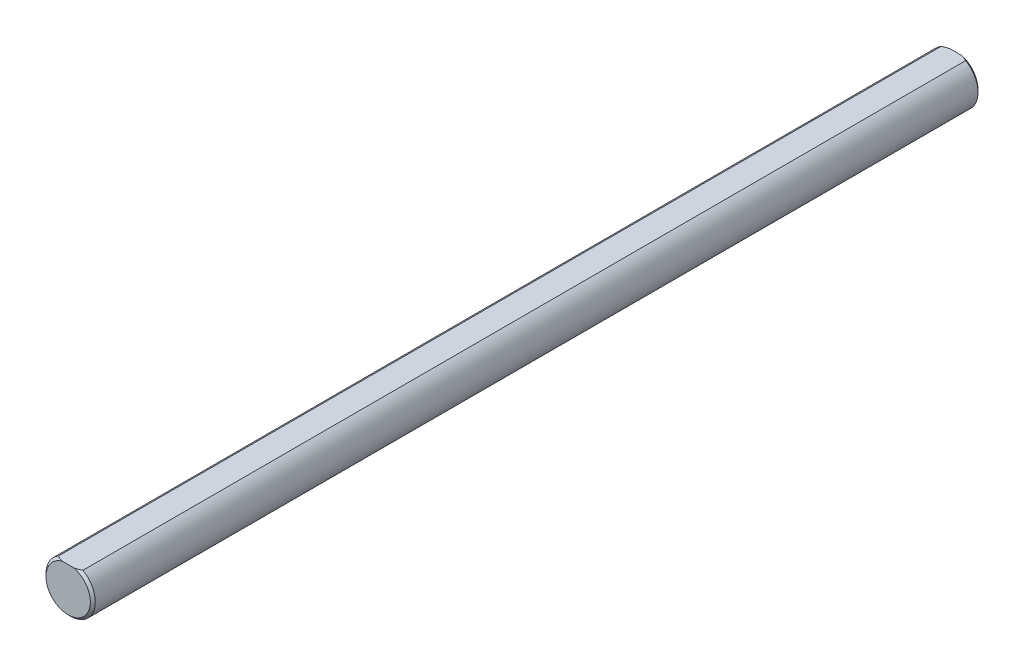
from build123d import *

# Parameters (mm, degrees)
SKETCH3_R                = 3.175
BOSS_EXTRUDE2_DEPTH      = 57.15
BOSS_EXTRUDE2_DEPTH_BACK = 57.15
CUT_EXTRUDE5_DEPTH       = 58.15
CUT_EXTRUDE5_DEPTH_BACK  = 58.15
CHAMFER1_SIZE            = 0.3175


with BuildPart() as part:
    # Sketch3 → Boss-Extrude2 (new body, two sides)
    with BuildSketch(Plane.XY) as boss_extrude2_sk:
        Circle(SKETCH3_R)
    extrude(amount=BOSS_EXTRUDE2_DEPTH)
    extrude(boss_extrude2_sk.sketch, amount=-BOSS_EXTRUDE2_DEPTH_BACK)

    # Sketch10 → Cut-Extrude5 (cut, two sides)
    with BuildSketch(Plane.XY) as cut_extrude5_sk:
        with BuildLine():
            Line((-1.5875, 2.749630657), (1.5875, 2.749630657))
            ThreePointArc((1.5875, 2.749630657), (0, 3.175), (-1.5875, 2.749630657))
        make_face()
    extrude(amount=CUT_EXTRUDE5_DEPTH, mode=Mode.SUBTRACT)
    extrude(cut_extrude5_sk.sketch, amount=-CUT_EXTRUDE5_DEPTH_BACK, mode=Mode.SUBTRACT)

    # Chamfer1
    chamfer1_edges = [part.edges().sort_by_distance(p)[0] for p in [
        (0, -3.175, -57.15),
        (0, -3.175, 57.15),
    ]]
    chamfer(chamfer1_edges, length=CHAMFER1_SIZE)


solid = part.part
